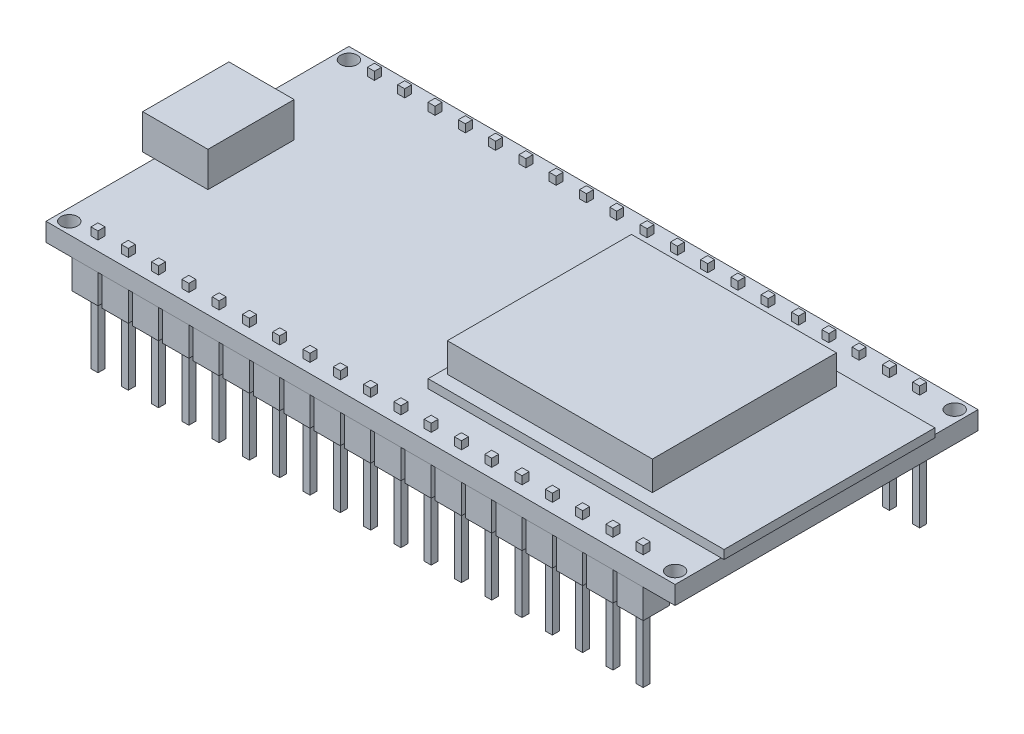
from build123d import *

# Parameters (mm, degrees)
SKETCH1_W                = 54
SKETCH1_H                = 26
BOSS_EXTRUDE1_DEPTH      = 0.785
SKETCH2_R                = 0.71
CUT_EXTRUDE1_DEPTH       = 2.57
MIRROR2_COPY_1_SKETCH_R  = 0.71
MIRROR2_COPY_1_DEPTH     = 2.57
SKETCH3_W                = 5.6
SKETCH3_H                = 7.4
BOSS_EXTRUDE2_DEPTH      = 3
SKETCH4_W                = 25.4
SKETCH4_H                = 18.1
BOSS_EXTRUDE3_DEPTH      = 0.75
SKETCH5_W                = 17.6
SKETCH5_H                = 15.8
BOSS_EXTRUDE4_DEPTH      = 2.5
SKETCH6_W                = 2.25
SKETCH6_H                = 2.25
BOSS_EXTRUDE5_DEPTH      = 2.5
BOSS_EXTRUDE6_START      = -4.75
SKETCH7_W                = 0.6
SKETCH7_H                = 0.6
BOSS_EXTRUDE6_DEPTH      = 10.55
LPATTERN1_COUNT          = 19
LPATTERN1_PITCH          = 2.6
MIRROR3_COPY_1_SKETCH_W  = 2.25
MIRROR3_COPY_1_SKETCH_H  = 2.25
MIRROR3_COPY_1_DEPTH     = 2.5
MIRROR3_COPY_2_SKETCH_W  = 2.25
MIRROR3_COPY_2_SKETCH_H  = 2.25
MIRROR3_COPY_2_DEPTH     = 2.5
MIRROR3_COPY_3_SKETCH_W  = 2.25
MIRROR3_COPY_3_SKETCH_H  = 2.25
MIRROR3_COPY_3_DEPTH     = 2.5
MIRROR3_COPY_4_SKETCH_W  = 2.25
MIRROR3_COPY_4_SKETCH_H  = 2.25
MIRROR3_COPY_4_DEPTH     = 2.5
MIRROR3_COPY_5_SKETCH_W  = 2.25
MIRROR3_COPY_5_SKETCH_H  = 2.25
MIRROR3_COPY_5_DEPTH     = 2.5
MIRROR3_COPY_6_SKETCH_W  = 2.25
MIRROR3_COPY_6_SKETCH_H  = 2.25
MIRROR3_COPY_6_DEPTH     = 2.5
MIRROR3_COPY_7_SKETCH_W  = 2.25
MIRROR3_COPY_7_SKETCH_H  = 2.25
MIRROR3_COPY_7_DEPTH     = 2.5
MIRROR3_COPY_8_SKETCH_W  = 2.25
MIRROR3_COPY_8_SKETCH_H  = 2.25
MIRROR3_COPY_8_DEPTH     = 2.5
MIRROR3_COPY_9_SKETCH_W  = 2.25
MIRROR3_COPY_9_SKETCH_H  = 2.25
MIRROR3_COPY_9_DEPTH     = 2.5
MIRROR3_COPY_10_SKETCH_W = 2.25
MIRROR3_COPY_10_SKETCH_H = 2.25
MIRROR3_COPY_10_DEPTH    = 2.5
MIRROR3_COPY_11_SKETCH_W = 2.25
MIRROR3_COPY_11_SKETCH_H = 2.25
MIRROR3_COPY_11_DEPTH    = 2.5
MIRROR3_COPY_12_SKETCH_W = 2.25
MIRROR3_COPY_12_SKETCH_H = 2.25
MIRROR3_COPY_12_DEPTH    = 2.5
MIRROR3_COPY_13_SKETCH_W = 2.25
MIRROR3_COPY_13_SKETCH_H = 2.25
MIRROR3_COPY_13_DEPTH    = 2.5
MIRROR3_COPY_14_SKETCH_W = 2.25
MIRROR3_COPY_14_SKETCH_H = 2.25
MIRROR3_COPY_14_DEPTH    = 2.5
MIRROR3_COPY_15_SKETCH_W = 2.25
MIRROR3_COPY_15_SKETCH_H = 2.25
MIRROR3_COPY_15_DEPTH    = 2.5
MIRROR3_COPY_16_SKETCH_W = 2.25
MIRROR3_COPY_16_SKETCH_H = 2.25
MIRROR3_COPY_16_DEPTH    = 2.5
MIRROR3_COPY_17_SKETCH_W = 2.25
MIRROR3_COPY_17_SKETCH_H = 2.25
MIRROR3_COPY_17_DEPTH    = 2.5
MIRROR3_COPY_18_SKETCH_W = 2.25
MIRROR3_COPY_18_SKETCH_H = 2.25
MIRROR3_COPY_18_DEPTH    = 2.5
MIRROR3_START            = -4.75
MIRROR3_COPY_19_SKETCH_W = 0.6
MIRROR3_COPY_19_SKETCH_H = 0.6
MIRROR3_COPY_19_DEPTH    = 10.55
MIRROR3_COPY_20_SKETCH_W = 0.6
MIRROR3_COPY_20_SKETCH_H = 0.6
MIRROR3_COPY_20_DEPTH    = 10.55
MIRROR3_COPY_21_SKETCH_W = 0.6
MIRROR3_COPY_21_SKETCH_H = 0.6
MIRROR3_COPY_21_DEPTH    = 10.55
MIRROR3_COPY_22_SKETCH_W = 0.6
MIRROR3_COPY_22_SKETCH_H = 0.6
MIRROR3_COPY_22_DEPTH    = 10.55
MIRROR3_COPY_23_SKETCH_W = 0.6
MIRROR3_COPY_23_SKETCH_H = 0.6
MIRROR3_COPY_23_DEPTH    = 10.55
MIRROR3_COPY_24_SKETCH_W = 0.6
MIRROR3_COPY_24_SKETCH_H = 0.6
MIRROR3_COPY_24_DEPTH    = 10.55
MIRROR3_COPY_25_SKETCH_W = 0.6
MIRROR3_COPY_25_SKETCH_H = 0.6
MIRROR3_COPY_25_DEPTH    = 10.55
MIRROR3_COPY_26_SKETCH_W = 0.6
MIRROR3_COPY_26_SKETCH_H = 0.6
MIRROR3_COPY_26_DEPTH    = 10.55
MIRROR3_COPY_27_SKETCH_W = 0.6
MIRROR3_COPY_27_SKETCH_H = 0.6
MIRROR3_COPY_27_DEPTH    = 10.55
MIRROR3_COPY_28_SKETCH_W = 0.6
MIRROR3_COPY_28_SKETCH_H = 0.6
MIRROR3_COPY_28_DEPTH    = 10.55
MIRROR3_COPY_29_SKETCH_W = 0.6
MIRROR3_COPY_29_SKETCH_H = 0.6
MIRROR3_COPY_29_DEPTH    = 10.55
MIRROR3_COPY_30_SKETCH_W = 0.6
MIRROR3_COPY_30_SKETCH_H = 0.6
MIRROR3_COPY_30_DEPTH    = 10.55
MIRROR3_COPY_31_SKETCH_W = 0.6
MIRROR3_COPY_31_SKETCH_H = 0.6
MIRROR3_COPY_31_DEPTH    = 10.55
MIRROR3_COPY_32_SKETCH_W = 0.6
MIRROR3_COPY_32_SKETCH_H = 0.6
MIRROR3_COPY_32_DEPTH    = 10.55
MIRROR3_COPY_33_SKETCH_W = 0.6
MIRROR3_COPY_33_SKETCH_H = 0.6
MIRROR3_COPY_33_DEPTH    = 10.55
MIRROR3_COPY_34_SKETCH_W = 0.6
MIRROR3_COPY_34_SKETCH_H = 0.6
MIRROR3_COPY_34_DEPTH    = 10.55
MIRROR3_COPY_35_SKETCH_W = 0.6
MIRROR3_COPY_35_SKETCH_H = 0.6
MIRROR3_COPY_35_DEPTH    = 10.55
MIRROR3_COPY_36_SKETCH_W = 0.6
MIRROR3_COPY_36_SKETCH_H = 0.6
MIRROR3_COPY_36_DEPTH    = 10.55


with BuildPart() as part:
    # Sketch1 → Boss-Extrude1 (new body, symmetric)
    with BuildSketch(Plane(origin=(0, 0, 0), x_dir=(1, 0, 0), z_dir=(0, 1, 0))):
        Rectangle(SKETCH1_W, SKETCH1_H)
    extrude(amount=BOSS_EXTRUDE1_DEPTH, both=True)

    # Sketch2 → Cut-Extrude1 (cut, through all)
    with BuildSketch(Plane(origin=(0, 0.785, 0), x_dir=(1, 0, 0), z_dir=(0, 1, 0))):
        with Locations((-26, 12)):
            Circle(SKETCH2_R)
    cut_extrude1 = extrude(amount=-CUT_EXTRUDE1_DEPTH, mode=Mode.SUBTRACT)

    # Mirror1: Cut-Extrude1 across plane
    add(cut_extrude1.mirror(Plane(origin=(0, 0, 0), x_dir=(0, 0, 1), z_dir=(1, 0, 0))), mode=Mode.SUBTRACT)

    # Mirror2: Cut-Extrude1 across plane
    add(cut_extrude1.mirror(Plane.XY), mode=Mode.SUBTRACT)

    # Mirror2 copy 1 sketch → Mirror2 copy 1 (cut, through all)
    with BuildSketch(Plane(origin=(0, 0.785, 0), x_dir=(-1, 0, 0), z_dir=(0, 1, 0))):
        with Locations((-26, 12)):
            Circle(MIRROR2_COPY_1_SKETCH_R)
    extrude(amount=-MIRROR2_COPY_1_DEPTH, mode=Mode.SUBTRACT)

    # Sketch3 → Boss-Extrude2 (add)
    with BuildSketch(Plane(origin=(0, 0.785, 0), x_dir=(1, 0, 0), z_dir=(0, 1, 0))):
        with Locations((-25.2, 0)):
            Rectangle(SKETCH3_W, SKETCH3_H)
    extrude(amount=BOSS_EXTRUDE2_DEPTH)

    # Sketch4 → Boss-Extrude3 (add)
    with BuildSketch(Plane(origin=(0, 0.785, 0), x_dir=(1, 0, 0), z_dir=(0, 1, 0))):
        with Locations((14.55, 0)):
            Rectangle(SKETCH4_W, SKETCH4_H)
    extrude(amount=BOSS_EXTRUDE3_DEPTH)

    # Sketch5 → Boss-Extrude4 (add)
    with BuildSketch(Plane(origin=(0, 1.535, 0), x_dir=(1, 0, 0), z_dir=(0, 1, 0))):
        with Locations((11.15, 0)):
            Rectangle(SKETCH5_W, SKETCH5_H)
    extrude(amount=BOSS_EXTRUDE4_DEPTH)

    # Sketch6 → Boss-Extrude5 (add)
    with BuildSketch(Plane.XZ.offset(0.785)):
        with Locations((-23.673788287, -11.865)):
            Rectangle(SKETCH6_W, SKETCH6_H)
    boss_extrude5 = extrude(amount=BOSS_EXTRUDE5_DEPTH)

    # Sketch7 → Boss-Extrude6 (add)
    with BuildSketch(Plane.XZ.offset(3.285).offset(BOSS_EXTRUDE6_START)):
        with Locations((-23.673788287, -11.865)):
            Rectangle(SKETCH7_W, SKETCH7_H)
    boss_extrude6 = extrude(amount=BOSS_EXTRUDE6_DEPTH)

    # LPattern1: Boss-Extrude5, Boss-Extrude6 ×19
    with Locations(*[(i * LPATTERN1_PITCH, 0, 0) for i in range(1, LPATTERN1_COUNT)]):
        add(boss_extrude5)
        add(boss_extrude6)

    # Mirror3: Boss-Extrude5, Boss-Extrude6 across plane
    add(boss_extrude5.mirror(Plane.XY))
    add(boss_extrude6.mirror(Plane.XY))

    # Mirror3 copy 1 sketch → Mirror3 copy 1 (add)
    with BuildSketch(Plane(origin=(2.6, -0.785, 0), x_dir=(1, 0, 0), z_dir=(0, -1, 0))):
        with Locations((-23.673788287, 11.865)):
            Rectangle(MIRROR3_COPY_1_SKETCH_W, MIRROR3_COPY_1_SKETCH_H)
    extrude(amount=MIRROR3_COPY_1_DEPTH)

    # Mirror3 copy 2 sketch → Mirror3 copy 2 (add)
    with BuildSketch(Plane(origin=(5.2, -0.785, 0), x_dir=(1, 0, 0), z_dir=(0, -1, 0))):
        with Locations((-23.673788287, 11.865)):
            Rectangle(MIRROR3_COPY_2_SKETCH_W, MIRROR3_COPY_2_SKETCH_H)
    extrude(amount=MIRROR3_COPY_2_DEPTH)

    # Mirror3 copy 3 sketch → Mirror3 copy 3 (add)
    with BuildSketch(Plane(origin=(7.8, -0.785, 0), x_dir=(1, 0, 0), z_dir=(0, -1, 0))):
        with Locations((-23.673788287, 11.865)):
            Rectangle(MIRROR3_COPY_3_SKETCH_W, MIRROR3_COPY_3_SKETCH_H)
    extrude(amount=MIRROR3_COPY_3_DEPTH)

    # Mirror3 copy 4 sketch → Mirror3 copy 4 (add)
    with BuildSketch(Plane(origin=(10.4, -0.785, 0), x_dir=(1, 0, 0), z_dir=(0, -1, 0))):
        with Locations((-23.673788287, 11.865)):
            Rectangle(MIRROR3_COPY_4_SKETCH_W, MIRROR3_COPY_4_SKETCH_H)
    extrude(amount=MIRROR3_COPY_4_DEPTH)

    # Mirror3 copy 5 sketch → Mirror3 copy 5 (add)
    with BuildSketch(Plane(origin=(13, -0.785, 0), x_dir=(1, 0, 0), z_dir=(0, -1, 0))):
        with Locations((-23.673788287, 11.865)):
            Rectangle(MIRROR3_COPY_5_SKETCH_W, MIRROR3_COPY_5_SKETCH_H)
    extrude(amount=MIRROR3_COPY_5_DEPTH)

    # Mirror3 copy 6 sketch → Mirror3 copy 6 (add)
    with BuildSketch(Plane(origin=(15.6, -0.785, 0), x_dir=(1, 0, 0), z_dir=(0, -1, 0))):
        with Locations((-23.673788287, 11.865)):
            Rectangle(MIRROR3_COPY_6_SKETCH_W, MIRROR3_COPY_6_SKETCH_H)
    extrude(amount=MIRROR3_COPY_6_DEPTH)

    # Mirror3 copy 7 sketch → Mirror3 copy 7 (add)
    with BuildSketch(Plane(origin=(18.2, -0.785, 0), x_dir=(1, 0, 0), z_dir=(0, -1, 0))):
        with Locations((-23.673788287, 11.865)):
            Rectangle(MIRROR3_COPY_7_SKETCH_W, MIRROR3_COPY_7_SKETCH_H)
    extrude(amount=MIRROR3_COPY_7_DEPTH)

    # Mirror3 copy 8 sketch → Mirror3 copy 8 (add)
    with BuildSketch(Plane(origin=(20.8, -0.785, 0), x_dir=(1, 0, 0), z_dir=(0, -1, 0))):
        with Locations((-23.673788287, 11.865)):
            Rectangle(MIRROR3_COPY_8_SKETCH_W, MIRROR3_COPY_8_SKETCH_H)
    extrude(amount=MIRROR3_COPY_8_DEPTH)

    # Mirror3 copy 9 sketch → Mirror3 copy 9 (add)
    with BuildSketch(Plane(origin=(23.4, -0.785, 0), x_dir=(1, 0, 0), z_dir=(0, -1, 0))):
        with Locations((-23.673788287, 11.865)):
            Rectangle(MIRROR3_COPY_9_SKETCH_W, MIRROR3_COPY_9_SKETCH_H)
    extrude(amount=MIRROR3_COPY_9_DEPTH)

    # Mirror3 copy 10 sketch → Mirror3 copy 10 (add)
    with BuildSketch(Plane(origin=(26, -0.785, 0), x_dir=(1, 0, 0), z_dir=(0, -1, 0))):
        with Locations((-23.673788287, 11.865)):
            Rectangle(MIRROR3_COPY_10_SKETCH_W, MIRROR3_COPY_10_SKETCH_H)
    extrude(amount=MIRROR3_COPY_10_DEPTH)

    # Mirror3 copy 11 sketch → Mirror3 copy 11 (add)
    with BuildSketch(Plane(origin=(28.6, -0.785, 0), x_dir=(1, 0, 0), z_dir=(0, -1, 0))):
        with Locations((-23.673788287, 11.865)):
            Rectangle(MIRROR3_COPY_11_SKETCH_W, MIRROR3_COPY_11_SKETCH_H)
    extrude(amount=MIRROR3_COPY_11_DEPTH)

    # Mirror3 copy 12 sketch → Mirror3 copy 12 (add)
    with BuildSketch(Plane(origin=(31.2, -0.785, 0), x_dir=(1, 0, 0), z_dir=(0, -1, 0))):
        with Locations((-23.673788287, 11.865)):
            Rectangle(MIRROR3_COPY_12_SKETCH_W, MIRROR3_COPY_12_SKETCH_H)
    extrude(amount=MIRROR3_COPY_12_DEPTH)

    # Mirror3 copy 13 sketch → Mirror3 copy 13 (add)
    with BuildSketch(Plane(origin=(33.8, -0.785, 0), x_dir=(1, 0, 0), z_dir=(0, -1, 0))):
        with Locations((-23.673788287, 11.865)):
            Rectangle(MIRROR3_COPY_13_SKETCH_W, MIRROR3_COPY_13_SKETCH_H)
    extrude(amount=MIRROR3_COPY_13_DEPTH)

    # Mirror3 copy 14 sketch → Mirror3 copy 14 (add)
    with BuildSketch(Plane(origin=(36.4, -0.785, 0), x_dir=(1, 0, 0), z_dir=(0, -1, 0))):
        with Locations((-23.673788287, 11.865)):
            Rectangle(MIRROR3_COPY_14_SKETCH_W, MIRROR3_COPY_14_SKETCH_H)
    extrude(amount=MIRROR3_COPY_14_DEPTH)

    # Mirror3 copy 15 sketch → Mirror3 copy 15 (add)
    with BuildSketch(Plane(origin=(39, -0.785, 0), x_dir=(1, 0, 0), z_dir=(0, -1, 0))):
        with Locations((-23.673788287, 11.865)):
            Rectangle(MIRROR3_COPY_15_SKETCH_W, MIRROR3_COPY_15_SKETCH_H)
    extrude(amount=MIRROR3_COPY_15_DEPTH)

    # Mirror3 copy 16 sketch → Mirror3 copy 16 (add)
    with BuildSketch(Plane(origin=(41.6, -0.785, 0), x_dir=(1, 0, 0), z_dir=(0, -1, 0))):
        with Locations((-23.673788287, 11.865)):
            Rectangle(MIRROR3_COPY_16_SKETCH_W, MIRROR3_COPY_16_SKETCH_H)
    extrude(amount=MIRROR3_COPY_16_DEPTH)

    # Mirror3 copy 17 sketch → Mirror3 copy 17 (add)
    with BuildSketch(Plane(origin=(44.2, -0.785, 0), x_dir=(1, 0, 0), z_dir=(0, -1, 0))):
        with Locations((-23.673788287, 11.865)):
            Rectangle(MIRROR3_COPY_17_SKETCH_W, MIRROR3_COPY_17_SKETCH_H)
    extrude(amount=MIRROR3_COPY_17_DEPTH)

    # Mirror3 copy 18 sketch → Mirror3 copy 18 (add)
    with BuildSketch(Plane(origin=(46.8, -0.785, 0), x_dir=(1, 0, 0), z_dir=(0, -1, 0))):
        with Locations((-23.673788287, 11.865)):
            Rectangle(MIRROR3_COPY_18_SKETCH_W, MIRROR3_COPY_18_SKETCH_H)
    extrude(amount=MIRROR3_COPY_18_DEPTH)

    # Mirror3 copy 19 sketch → Mirror3 copy 19 (add)
    with BuildSketch(Plane(origin=(2.6, -3.285, 0), x_dir=(1, 0, 0), z_dir=(0, -1, 0)).offset(MIRROR3_START)):
        with Locations((-23.673788287, 11.865)):
            Rectangle(MIRROR3_COPY_19_SKETCH_W, MIRROR3_COPY_19_SKETCH_H)
    extrude(amount=MIRROR3_COPY_19_DEPTH)

    # Mirror3 copy 20 sketch → Mirror3 copy 20 (add)
    with BuildSketch(Plane(origin=(5.2, -3.285, 0), x_dir=(1, 0, 0), z_dir=(0, -1, 0)).offset(MIRROR3_START)):
        with Locations((-23.673788287, 11.865)):
            Rectangle(MIRROR3_COPY_20_SKETCH_W, MIRROR3_COPY_20_SKETCH_H)
    extrude(amount=MIRROR3_COPY_20_DEPTH)

    # Mirror3 copy 21 sketch → Mirror3 copy 21 (add)
    with BuildSketch(Plane(origin=(7.8, -3.285, 0), x_dir=(1, 0, 0), z_dir=(0, -1, 0)).offset(MIRROR3_START)):
        with Locations((-23.673788287, 11.865)):
            Rectangle(MIRROR3_COPY_21_SKETCH_W, MIRROR3_COPY_21_SKETCH_H)
    extrude(amount=MIRROR3_COPY_21_DEPTH)

    # Mirror3 copy 22 sketch → Mirror3 copy 22 (add)
    with BuildSketch(Plane(origin=(10.4, -3.285, 0), x_dir=(1, 0, 0), z_dir=(0, -1, 0)).offset(MIRROR3_START)):
        with Locations((-23.673788287, 11.865)):
            Rectangle(MIRROR3_COPY_22_SKETCH_W, MIRROR3_COPY_22_SKETCH_H)
    extrude(amount=MIRROR3_COPY_22_DEPTH)

    # Mirror3 copy 23 sketch → Mirror3 copy 23 (add)
    with BuildSketch(Plane(origin=(13, -3.285, 0), x_dir=(1, 0, 0), z_dir=(0, -1, 0)).offset(MIRROR3_START)):
        with Locations((-23.673788287, 11.865)):
            Rectangle(MIRROR3_COPY_23_SKETCH_W, MIRROR3_COPY_23_SKETCH_H)
    extrude(amount=MIRROR3_COPY_23_DEPTH)

    # Mirror3 copy 24 sketch → Mirror3 copy 24 (add)
    with BuildSketch(Plane(origin=(15.6, -3.285, 0), x_dir=(1, 0, 0), z_dir=(0, -1, 0)).offset(MIRROR3_START)):
        with Locations((-23.673788287, 11.865)):
            Rectangle(MIRROR3_COPY_24_SKETCH_W, MIRROR3_COPY_24_SKETCH_H)
    extrude(amount=MIRROR3_COPY_24_DEPTH)

    # Mirror3 copy 25 sketch → Mirror3 copy 25 (add)
    with BuildSketch(Plane(origin=(18.2, -3.285, 0), x_dir=(1, 0, 0), z_dir=(0, -1, 0)).offset(MIRROR3_START)):
        with Locations((-23.673788287, 11.865)):
            Rectangle(MIRROR3_COPY_25_SKETCH_W, MIRROR3_COPY_25_SKETCH_H)
    extrude(amount=MIRROR3_COPY_25_DEPTH)

    # Mirror3 copy 26 sketch → Mirror3 copy 26 (add)
    with BuildSketch(Plane(origin=(20.8, -3.285, 0), x_dir=(1, 0, 0), z_dir=(0, -1, 0)).offset(MIRROR3_START)):
        with Locations((-23.673788287, 11.865)):
            Rectangle(MIRROR3_COPY_26_SKETCH_W, MIRROR3_COPY_26_SKETCH_H)
    extrude(amount=MIRROR3_COPY_26_DEPTH)

    # Mirror3 copy 27 sketch → Mirror3 copy 27 (add)
    with BuildSketch(Plane(origin=(23.4, -3.285, 0), x_dir=(1, 0, 0), z_dir=(0, -1, 0)).offset(MIRROR3_START)):
        with Locations((-23.673788287, 11.865)):
            Rectangle(MIRROR3_COPY_27_SKETCH_W, MIRROR3_COPY_27_SKETCH_H)
    extrude(amount=MIRROR3_COPY_27_DEPTH)

    # Mirror3 copy 28 sketch → Mirror3 copy 28 (add)
    with BuildSketch(Plane(origin=(26, -3.285, 0), x_dir=(1, 0, 0), z_dir=(0, -1, 0)).offset(MIRROR3_START)):
        with Locations((-23.673788287, 11.865)):
            Rectangle(MIRROR3_COPY_28_SKETCH_W, MIRROR3_COPY_28_SKETCH_H)
    extrude(amount=MIRROR3_COPY_28_DEPTH)

    # Mirror3 copy 29 sketch → Mirror3 copy 29 (add)
    with BuildSketch(Plane(origin=(28.6, -3.285, 0), x_dir=(1, 0, 0), z_dir=(0, -1, 0)).offset(MIRROR3_START)):
        with Locations((-23.673788287, 11.865)):
            Rectangle(MIRROR3_COPY_29_SKETCH_W, MIRROR3_COPY_29_SKETCH_H)
    extrude(amount=MIRROR3_COPY_29_DEPTH)

    # Mirror3 copy 30 sketch → Mirror3 copy 30 (add)
    with BuildSketch(Plane(origin=(31.2, -3.285, 0), x_dir=(1, 0, 0), z_dir=(0, -1, 0)).offset(MIRROR3_START)):
        with Locations((-23.673788287, 11.865)):
            Rectangle(MIRROR3_COPY_30_SKETCH_W, MIRROR3_COPY_30_SKETCH_H)
    extrude(amount=MIRROR3_COPY_30_DEPTH)

    # Mirror3 copy 31 sketch → Mirror3 copy 31 (add)
    with BuildSketch(Plane(origin=(33.8, -3.285, 0), x_dir=(1, 0, 0), z_dir=(0, -1, 0)).offset(MIRROR3_START)):
        with Locations((-23.673788287, 11.865)):
            Rectangle(MIRROR3_COPY_31_SKETCH_W, MIRROR3_COPY_31_SKETCH_H)
    extrude(amount=MIRROR3_COPY_31_DEPTH)

    # Mirror3 copy 32 sketch → Mirror3 copy 32 (add)
    with BuildSketch(Plane(origin=(36.4, -3.285, 0), x_dir=(1, 0, 0), z_dir=(0, -1, 0)).offset(MIRROR3_START)):
        with Locations((-23.673788287, 11.865)):
            Rectangle(MIRROR3_COPY_32_SKETCH_W, MIRROR3_COPY_32_SKETCH_H)
    extrude(amount=MIRROR3_COPY_32_DEPTH)

    # Mirror3 copy 33 sketch → Mirror3 copy 33 (add)
    with BuildSketch(Plane(origin=(39, -3.285, 0), x_dir=(1, 0, 0), z_dir=(0, -1, 0)).offset(MIRROR3_START)):
        with Locations((-23.673788287, 11.865)):
            Rectangle(MIRROR3_COPY_33_SKETCH_W, MIRROR3_COPY_33_SKETCH_H)
    extrude(amount=MIRROR3_COPY_33_DEPTH)

    # Mirror3 copy 34 sketch → Mirror3 copy 34 (add)
    with BuildSketch(Plane(origin=(41.6, -3.285, 0), x_dir=(1, 0, 0), z_dir=(0, -1, 0)).offset(MIRROR3_START)):
        with Locations((-23.673788287, 11.865)):
            Rectangle(MIRROR3_COPY_34_SKETCH_W, MIRROR3_COPY_34_SKETCH_H)
    extrude(amount=MIRROR3_COPY_34_DEPTH)

    # Mirror3 copy 35 sketch → Mirror3 copy 35 (add)
    with BuildSketch(Plane(origin=(44.2, -3.285, 0), x_dir=(1, 0, 0), z_dir=(0, -1, 0)).offset(MIRROR3_START)):
        with Locations((-23.673788287, 11.865)):
            Rectangle(MIRROR3_COPY_35_SKETCH_W, MIRROR3_COPY_35_SKETCH_H)
    extrude(amount=MIRROR3_COPY_35_DEPTH)

    # Mirror3 copy 36 sketch → Mirror3 copy 36 (add)
    with BuildSketch(Plane(origin=(46.8, -3.285, 0), x_dir=(1, 0, 0), z_dir=(0, -1, 0)).offset(MIRROR3_START)):
        with Locations((-23.673788287, 11.865)):
            Rectangle(MIRROR3_COPY_36_SKETCH_W, MIRROR3_COPY_36_SKETCH_H)
    extrude(amount=MIRROR3_COPY_36_DEPTH)


solid = part.part
